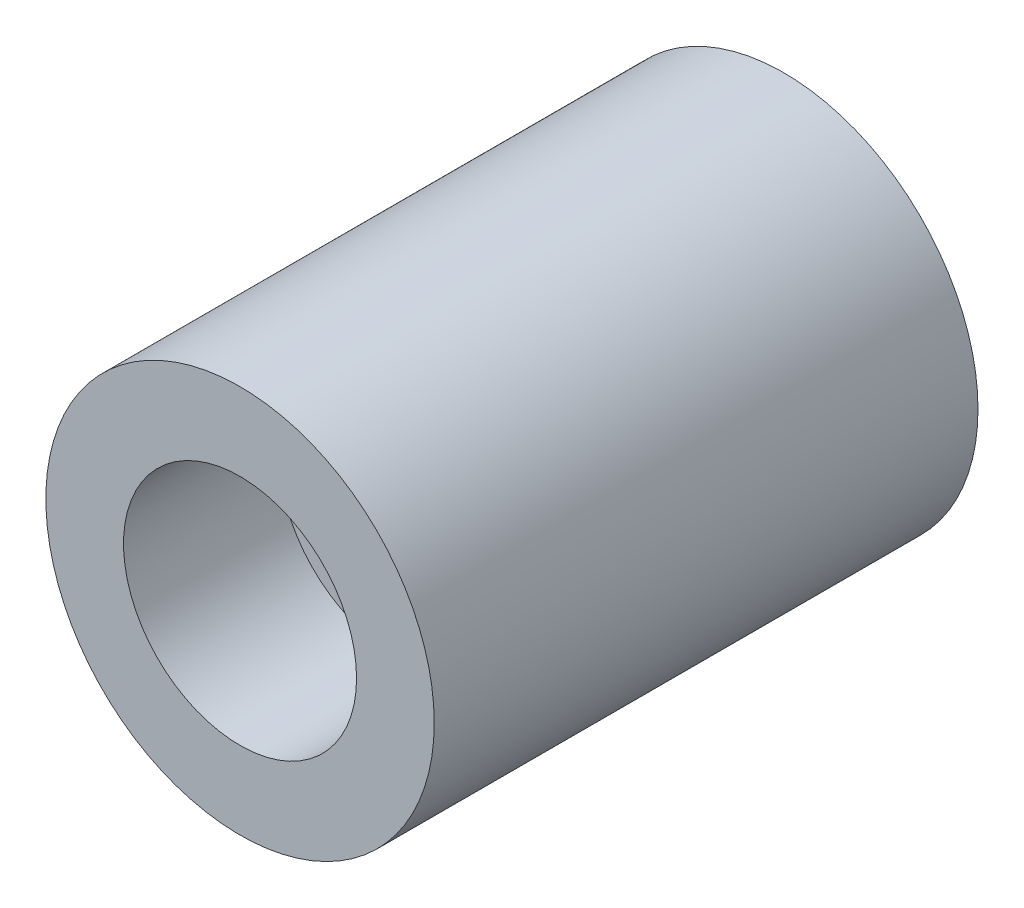
from build123d import *

# Parameters (mm, degrees)
SKETCH1_R           = 50
BOSS_EXTRUDE1_DEPTH = 140
SKETCH2_R           = 30
CUT_EXTRUDE1_DEPTH  = 40
SKETCH4_R           = 10
CUT_EXTRUDE2_DEPTH  = 120


with BuildPart() as part:
    # Sketch1 → Boss-Extrude1 (new body)
    with BuildSketch(Plane.XY):
        Circle(SKETCH1_R)
    extrude(amount=BOSS_EXTRUDE1_DEPTH)

    # Sketch2 → Cut-Extrude1 (cut)
    with BuildSketch(Plane.XY.offset(140)):
        Circle(SKETCH2_R)
    extrude(amount=-CUT_EXTRUDE1_DEPTH, mode=Mode.SUBTRACT)

    # Sketch4 → Cut-Extrude2 (cut)
    with BuildSketch(Plane.XY.offset(140)):
        Circle(SKETCH4_R)
    extrude(amount=-CUT_EXTRUDE2_DEPTH, mode=Mode.SUBTRACT)


solid = part.part
